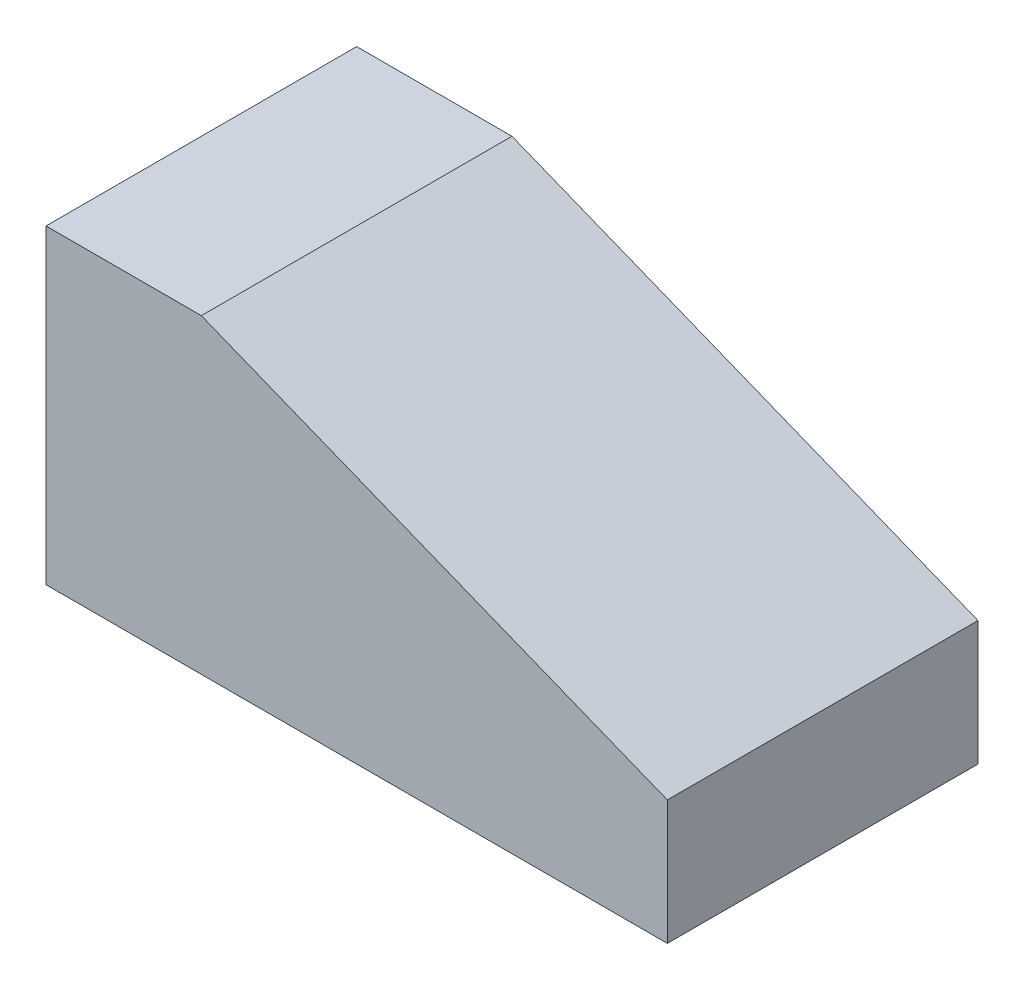
from build123d import *

# Parameters (mm, degrees)
BOSS_EXTRUDE1_DEPTH = 50


with BuildPart() as part:
    # Sketch1 → Boss-Extrude1 (new body)
    with BuildSketch(Plane.XY):
        Polygon((0, 0), (0, 50), (25, 50), (100, 20), (100, 0), align=None)
    extrude(amount=BOSS_EXTRUDE1_DEPTH)


solid = part.part
